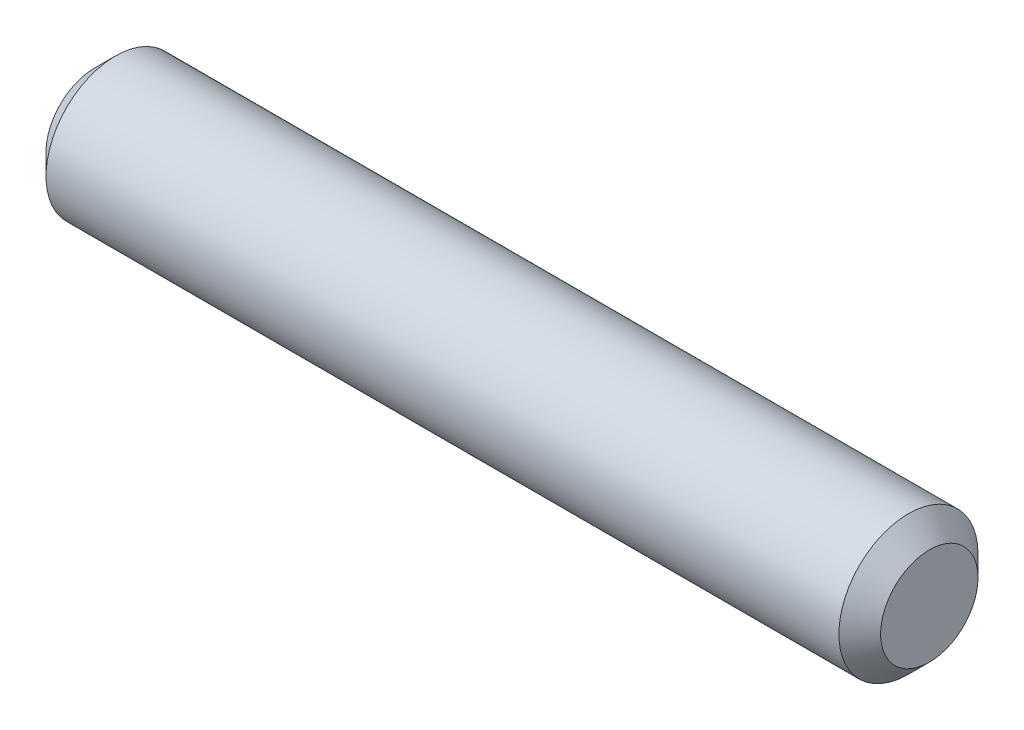
from build123d import *

# Parameters (mm, degrees)
SKETCH2_R                = 3.175
BOSS_EXTRUDE1_DEPTH      = 19.05
BOSS_EXTRUDE1_DEPTH_BACK = 19.05
CHAMFER1_SIZE            = 0.9525


with BuildPart() as part:
    # Sketch2 → Boss-Extrude1 (new body, two sides)
    with BuildSketch(Plane(origin=(0, 0, 0), x_dir=(0, 0, -1), z_dir=(1, 0, 0))) as boss_extrude1_sk:
        Circle(SKETCH2_R)
    extrude(amount=BOSS_EXTRUDE1_DEPTH)
    extrude(boss_extrude1_sk.sketch, amount=-BOSS_EXTRUDE1_DEPTH_BACK)

    # Chamfer1
    chamfer1_edges = [part.edges().sort_by_distance(p)[0] for p in [
        (-19.05, 0, 3.175),
        (19.05, 0, 3.175),
    ]]
    chamfer(chamfer1_edges, length=CHAMFER1_SIZE)


solid = part.part
